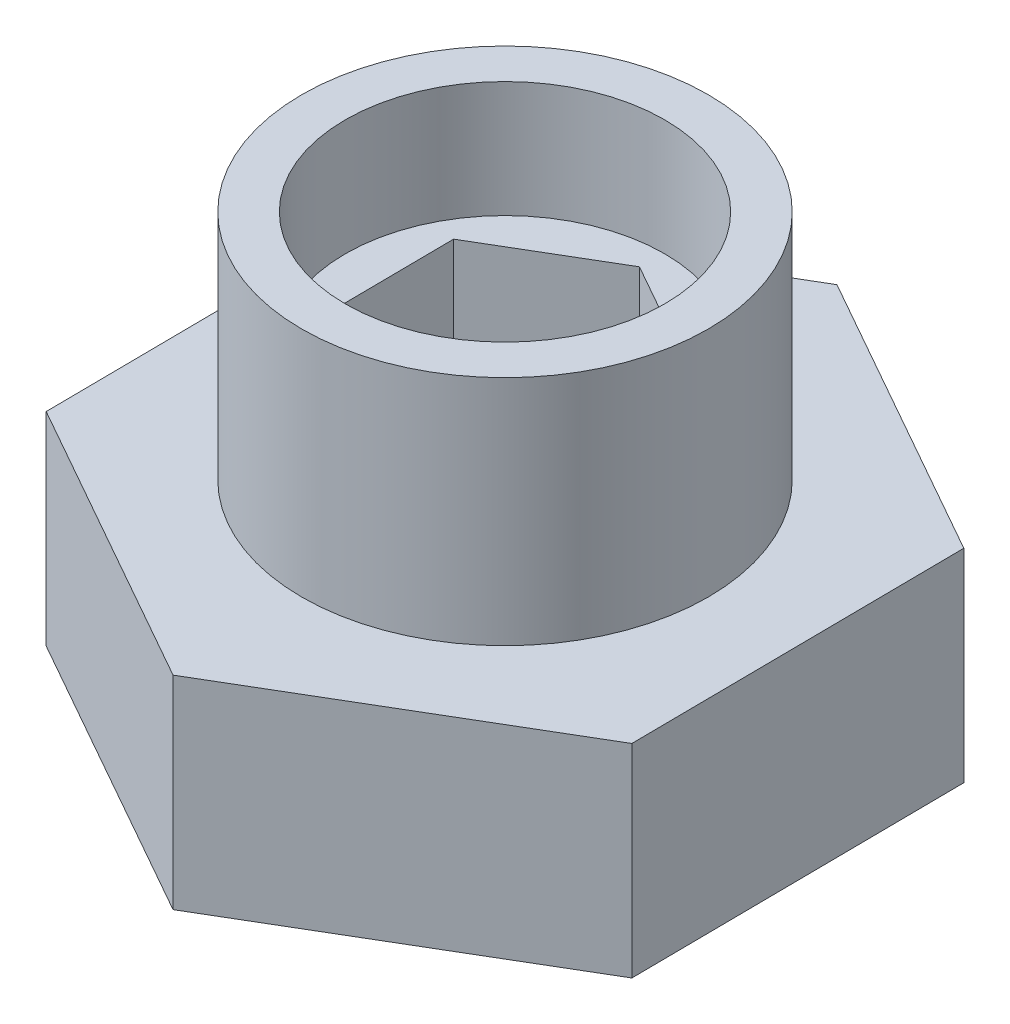
from build123d import *

# Parameters (mm, degrees)
BOSS_EXTRUDE1_DEPTH = 15
SKETCH3_OUTSIDE_W   = 28.926
SKETCH3_OUTSIDE_H   = 31.914
SKETCH3_OUTSIDE_R   = 7
CUT_EXTRUDE1_DEPTH  = 8
SKETCH4_R           = 5.5
CUT_EXTRUDE2_DEPTH  = 4
CUT_EXTRUDE3_DEPTH  = 4
SKETCH6_R           = 3
CUT_EXTRUDE4_DEPTH  = 8


with BuildPart() as part:
    # Sketch1 → Boss-Extrude1 (new body)
    with BuildSketch(Plane(origin=(0, 0, 0), x_dir=(1, 0, 0), z_dir=(0, 1, 0))):
        Polygon((9.946043617, 5.865965368), (-0.107053218, 11.546509124), (-10.053096835, 5.680543756), (-9.946043617, -5.865965368), (0.107053218, -11.546509124), (10.053096835, -5.680543756), align=None)
    extrude(amount=BOSS_EXTRUDE1_DEPTH)

    # Sketch3 outside → Cut-Extrude1 (cut)
    with BuildSketch(Plane(origin=(0, 15, 0), x_dir=(1, 0, 0), z_dir=(0, 1, 0))):
        Rectangle(SKETCH3_OUTSIDE_W, SKETCH3_OUTSIDE_H)
        Circle(SKETCH3_OUTSIDE_R, mode=Mode.SUBTRACT)
    extrude(amount=-CUT_EXTRUDE1_DEPTH, mode=Mode.SUBTRACT)

    # Sketch4 → Cut-Extrude2 (cut)
    with BuildSketch(Plane(origin=(0, 15, 0), x_dir=(1, 0, 0), z_dir=(0, 1, 0))):
        Circle(SKETCH4_R)
    extrude(amount=-CUT_EXTRUDE2_DEPTH, mode=Mode.SUBTRACT)

    # Sketch5 → Cut-Extrude3 (cut)
    with BuildSketch(Plane(origin=(0, 11, 0), x_dir=(1, 0, 0), z_dir=(0, 1, 0))):
        Polygon((-4.071504218, 2.300620221), (-4.028147665, -2.375715974), (0.043356553, -4.676336195), (4.071504218, -2.300620221), (4.028147665, 2.375715974), (-0.043356553, 4.676336195), align=None)
    extrude(amount=-CUT_EXTRUDE3_DEPTH, mode=Mode.SUBTRACT)

    # Sketch6 → Cut-Extrude4 (cut, through all)
    with BuildSketch(Plane(origin=(0, 7, 0), x_dir=(1, 0, 0), z_dir=(0, 1, 0))):
        Circle(SKETCH6_R)
    extrude(amount=-CUT_EXTRUDE4_DEPTH, mode=Mode.SUBTRACT)


solid = part.part
